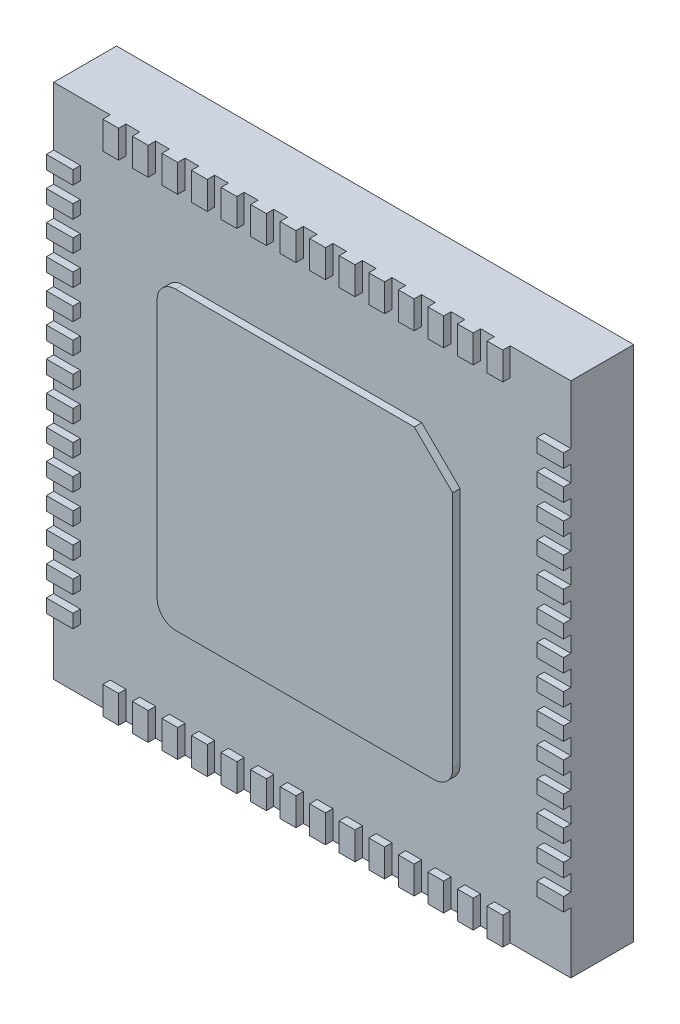
from build123d import *

# Parameters (mm, degrees)
PACKAGE_W               = 7
PACKAGE_H               = 7
BOSS_EXTRU_1_DEPTH      = 0.85
ESQUISSE2_W             = 0.213586618
ESQUISSE2_H             = 0.374942299
ESQUISSE2_W_2           = 0.360094548
ESQUISSE2_H_2           = 0.182510236
ESQUISSE2_W_3           = 0.360094549
BOSS_EXTRU_2_DEPTH      = 0.1
ESQUISSE3_R             = 0.166069215
ENL_V_MAT_EXTRU_1_DEPTH = 0.1
ENL_V_MAT_EXTRU_2_DEPTH = 0.02


with BuildPart() as part:
    # package → Boss.-Extru.1 (new body)
    with BuildSketch(Plane.XY):
        with Locations((26.809198807, 233.44048648)):
            Rectangle(PACKAGE_W, PACKAGE_H)
    extrude(amount=-BOSS_EXTRU_1_DEPTH)

    # Esquisse2 → Boss.-Extru.2 (add)
    with BuildSketch(Plane.XY):
        with BuildLine():
            Line((25.059198807, 231.44048648), (28.559198807, 231.44048648))
            ThreePointArc((28.559198807, 231.44048648), (28.735975502, 231.513709785), (28.809198807, 231.69048648))
            Line((28.809198807, 231.69048648), (28.809198807, 234.928046777))
            Line((28.809198807, 234.928046777), (28.290211106, 235.44048648))
            Line((28.290211106, 235.44048648), (25.059198807, 235.44048648))
            ThreePointArc((25.059198807, 235.44048648), (24.882422111, 235.367263175), (24.809198807, 235.19048648))
            Line((24.809198807, 235.19048648), (24.809198807, 231.69048648))
            ThreePointArc((24.809198807, 231.69048648), (24.882422111, 231.513709785), (25.059198807, 231.44048648))
        make_face()
        with Locations((24.180646365, 236.753015331)):
            Rectangle(ESQUISSE2_W, ESQUISSE2_H)
        with Locations((24.580646365, 236.753015331)):
            Rectangle(ESQUISSE2_W, ESQUISSE2_H)
        with Locations((24.980646365, 236.753015331)):
            Rectangle(ESQUISSE2_W, ESQUISSE2_H)
        with Locations((25.380646365, 236.753015331)):
            Rectangle(ESQUISSE2_W, ESQUISSE2_H)
        with Locations((25.780646365, 236.753015331)):
            Rectangle(ESQUISSE2_W, ESQUISSE2_H)
        with Locations((26.180646365, 236.753015331)):
            Rectangle(ESQUISSE2_W, ESQUISSE2_H)
        with Locations((26.580646365, 236.753015331)):
            Rectangle(ESQUISSE2_W, ESQUISSE2_H)
        with Locations((26.980646365, 236.753015331)):
            Rectangle(ESQUISSE2_W, ESQUISSE2_H)
        with Locations((27.380646365, 236.753015331)):
            Rectangle(ESQUISSE2_W, ESQUISSE2_H)
        with Locations((27.780646365, 236.753015331)):
            Rectangle(ESQUISSE2_W, ESQUISSE2_H)
        with Locations((28.180646365, 236.753015331)):
            Rectangle(ESQUISSE2_W, ESQUISSE2_H)
        with Locations((28.580646365, 236.753015331)):
            Rectangle(ESQUISSE2_W, ESQUISSE2_H)
        with Locations((28.980646365, 236.753015331)):
            Rectangle(ESQUISSE2_W, ESQUISSE2_H)
        with Locations((29.380646365, 236.753015331)):
            Rectangle(ESQUISSE2_W, ESQUISSE2_H)
        with Locations((23.489246081, 235.654646382)):
            Rectangle(ESQUISSE2_W_2, ESQUISSE2_H_2)
        with Locations((23.489246081, 236.054646382)):
            Rectangle(ESQUISSE2_W_2, ESQUISSE2_H_2)
        with Locations((23.489246081, 235.254646382)):
            Rectangle(ESQUISSE2_W_2, ESQUISSE2_H_2)
        with Locations((23.489246081, 234.854646382)):
            Rectangle(ESQUISSE2_W_2, ESQUISSE2_H_2)
        with Locations((23.489246081, 234.454646382)):
            Rectangle(ESQUISSE2_W_2, ESQUISSE2_H_2)
        with Locations((23.489246081, 234.054646382)):
            Rectangle(ESQUISSE2_W_2, ESQUISSE2_H_2)
        with Locations((23.489246081, 233.654646382)):
            Rectangle(ESQUISSE2_W_2, ESQUISSE2_H_2)
        with Locations((23.489246081, 233.254646382)):
            Rectangle(ESQUISSE2_W_2, ESQUISSE2_H_2)
        with Locations((23.489246081, 232.854646382)):
            Rectangle(ESQUISSE2_W_2, ESQUISSE2_H_2)
        with Locations((23.489246081, 232.454646382)):
            Rectangle(ESQUISSE2_W_2, ESQUISSE2_H_2)
        with Locations((23.489246081, 232.054646382)):
            Rectangle(ESQUISSE2_W_2, ESQUISSE2_H_2)
        with Locations((23.489246081, 231.654646382)):
            Rectangle(ESQUISSE2_W_2, ESQUISSE2_H_2)
        with Locations((23.489246081, 231.254646382)):
            Rectangle(ESQUISSE2_W_2, ESQUISSE2_H_2)
        with Locations((23.489246081, 230.854646382)):
            Rectangle(ESQUISSE2_W_2, ESQUISSE2_H_2)
        with Locations((29.380646365, 230.12795763)):
            Rectangle(ESQUISSE2_W, ESQUISSE2_H)
        with Locations((28.980646365, 230.12795763)):
            Rectangle(ESQUISSE2_W, ESQUISSE2_H)
        with Locations((28.580646365, 230.12795763)):
            Rectangle(ESQUISSE2_W, ESQUISSE2_H)
        with Locations((28.180646365, 230.12795763)):
            Rectangle(ESQUISSE2_W, ESQUISSE2_H)
        with Locations((27.780646365, 230.12795763)):
            Rectangle(ESQUISSE2_W, ESQUISSE2_H)
        with Locations((27.380646365, 230.12795763)):
            Rectangle(ESQUISSE2_W, ESQUISSE2_H)
        with Locations((26.980646365, 230.12795763)):
            Rectangle(ESQUISSE2_W, ESQUISSE2_H)
        with Locations((26.580646365, 230.12795763)):
            Rectangle(ESQUISSE2_W, ESQUISSE2_H)
        with Locations((26.180646365, 230.12795763)):
            Rectangle(ESQUISSE2_W, ESQUISSE2_H)
        with Locations((25.780646365, 230.12795763)):
            Rectangle(ESQUISSE2_W, ESQUISSE2_H)
        with Locations((25.380646365, 230.12795763)):
            Rectangle(ESQUISSE2_W, ESQUISSE2_H)
        with Locations((24.980646365, 230.12795763)):
            Rectangle(ESQUISSE2_W, ESQUISSE2_H)
        with Locations((24.580646365, 230.12795763)):
            Rectangle(ESQUISSE2_W, ESQUISSE2_H)
        with Locations((24.180646365, 230.12795763)):
            Rectangle(ESQUISSE2_W, ESQUISSE2_H)
        with Locations((30.129151533, 230.854646382)):
            Rectangle(ESQUISSE2_W_3, ESQUISSE2_H_2)
        with Locations((30.129151533, 231.254646382)):
            Rectangle(ESQUISSE2_W_3, ESQUISSE2_H_2)
        with Locations((30.129151533, 231.654646382)):
            Rectangle(ESQUISSE2_W_3, ESQUISSE2_H_2)
        with Locations((30.129151533, 232.054646382)):
            Rectangle(ESQUISSE2_W_3, ESQUISSE2_H_2)
        with Locations((30.129151533, 232.454646382)):
            Rectangle(ESQUISSE2_W_3, ESQUISSE2_H_2)
        with Locations((30.129151533, 232.854646382)):
            Rectangle(ESQUISSE2_W_3, ESQUISSE2_H_2)
        with Locations((30.129151533, 233.254646382)):
            Rectangle(ESQUISSE2_W_3, ESQUISSE2_H_2)
        with Locations((30.129151533, 233.654646382)):
            Rectangle(ESQUISSE2_W_3, ESQUISSE2_H_2)
        with Locations((30.129151533, 234.054646382)):
            Rectangle(ESQUISSE2_W_3, ESQUISSE2_H_2)
        with Locations((30.129151533, 234.454646382)):
            Rectangle(ESQUISSE2_W_3, ESQUISSE2_H_2)
        with Locations((30.129151533, 234.854646382)):
            Rectangle(ESQUISSE2_W_3, ESQUISSE2_H_2)
        with Locations((30.129151533, 235.254646382)):
            Rectangle(ESQUISSE2_W_3, ESQUISSE2_H_2)
        with Locations((30.129151533, 235.654646382)):
            Rectangle(ESQUISSE2_W_3, ESQUISSE2_H_2)
        with Locations((30.129151533, 236.054646382)):
            Rectangle(ESQUISSE2_W_3, ESQUISSE2_H_2)
    extrude(amount=BOSS_EXTRU_2_DEPTH)

    # Esquisse3 → Enlèv. mat.-Extru.1 (cut)
    with BuildSketch(Plane(origin=(0, 0, -0.85), x_dir=(-1, 0, 0), z_dir=(0, 0, -1))):
        with Locations((-29.974611492, 236.581266458)):
            Circle(ESQUISSE3_R)
    extrude(amount=-ENL_V_MAT_EXTRU_1_DEPTH, mode=Mode.SUBTRACT)

    # Esquisse4 → Enlèv. mat.-Extru.2 (cut)
    with BuildSketch(Plane(origin=(-0.370356703, 1.102355834, -0.85), x_dir=(-1, 0, 0), z_dir=(0, 0, -1))):
        Polygon((-28.682895901, 230.452000635), (-28.686659901, 230.484713635), (-28.838331901, 230.480821635), (-28.990003901, 230.476927635), (-28.990003901, 230.596414635), (-28.990003901, 230.715902635), (-28.856175901, 230.719267635), (-28.722347901, 230.722633635), (-28.722347901, 230.752370635), (-28.722347901, 230.782109635), (-28.856175901, 230.785472635), (-28.990003901, 230.788837635), (-28.990003901, 230.901457635), (-28.990003901, 231.014078635), (-28.841305901, 231.014078635), (-28.692607901, 231.014078635), (-28.692607901, 231.043818635), (-28.692607901, 231.073557635), (-28.876993901, 231.073557635), (-29.061378901, 231.073557635), (-29.061378901, 230.746422635), (-29.061378901, 230.419287635), (-28.870255901, 230.419287635), (-28.679131901, 230.419287635), align=None)
        with BuildLine():
            Line((-28.038336901, 230.556089635), (-28.038336901, 230.692890635))
            Line((-28.038336901, 230.692890635), (-27.936045901, 230.692890635))
            add(Edge.make_bspline(
                [(-27.936045901, 230.692890635), (-27.765671901, 230.692890635), (-27.699306901, 230.744596635), (-27.699384901, 230.877275635)],
                knots=[0, 0, 0, 0, 1, 1, 1, 1], degree=3))
            add(Edge.make_bspline(
                [(-27.699384901, 230.877275635), (-27.699473901, 230.963355635), (-27.727885901, 231.019005635), (-27.788523901, 231.051635635)],
                knots=[0, 0, 0, 0, 1, 1, 1, 1], degree=3))
            add(Edge.make_bspline(
                [(-27.788523901, 231.051635635), (-27.823602901, 231.070510635), (-27.851561901, 231.073534635), (-27.966063901, 231.070822635)],
                knots=[0, 0, 0, 0, 1, 1, 1, 1], degree=3))
            Line((-27.966063901, 231.070822635), (-28.101966901, 231.067608635))
            Line((-28.101966901, 231.067608635), (-28.099929901, 230.746420635))
            add(Edge.make_bspline(
                [(-28.099929901, 230.746420635), (-28.098817901, 230.569767635), (-28.097865901, 230.423895635), (-28.097865901, 230.422259635)],
                knots=[0, 0, 0, 0, 1, 1, 1, 1], degree=3))
            add(Edge.make_bspline(
                [(-28.097865901, 230.422259635), (-28.097865901, 230.420618635), (-28.084442901, 230.419285635), (-28.068085901, 230.419285635)],
                knots=[0, 0, 0, 0, 1, 1, 1, 1], degree=3))
            Line((-28.068085901, 230.419285635), (-28.038346901, 230.419285635))
            Line((-28.038346901, 230.419285635), (-28.038336901, 230.556089635))
        make_face()
        with BuildLine():
            Line((-28.038336901, 230.883224635), (-28.038336901, 231.014076635))
            Line((-28.038336901, 231.014076635), (-27.948527901, 231.014076635))
            add(Edge.make_bspline(
                [(-27.948527901, 231.014076635), (-27.816620901, 231.014076635), (-27.764732901, 230.977134635), (-27.764732901, 230.883222635)],
                knots=[0, 0, 0, 0, 1, 1, 1, 1], degree=3))
            add(Edge.make_bspline(
                [(-27.764732901, 230.883222635), (-27.764732901, 230.789310635), (-27.816620901, 230.752368635), (-27.948527901, 230.752368635)],
                knots=[0, 0, 0, 0, 1, 1, 1, 1], degree=3))
            Line((-27.948527901, 230.752368635), (-28.038336901, 230.752368635))
            Line((-28.038336901, 230.752368635), (-28.038336901, 230.883224635))
        make_face(mode=Mode.SUBTRACT)
        with BuildLine():
            Line((-26.848753901, 230.452550635), (-26.848753901, 230.485813635))
            Line((-26.848753901, 230.485813635), (-26.961421901, 230.480884635))
            add(Edge.make_bspline(
                [(-26.961421901, 230.480884635), (-27.105904901, 230.474566635), (-27.117372901, 230.478476635), (-27.092930901, 230.525741635)],
                knots=[0, 0, 0, 0, 1, 1, 1, 1], degree=3))
            add(Edge.make_bspline(
                [(-27.092930901, 230.525741635), (-27.082831901, 230.545270635), (-27.034841901, 230.603731635), (-26.986284901, 230.655653635)],
                knots=[0, 0, 0, 0, 1, 1, 1, 1], degree=3))
            add(Edge.make_bspline(
                [(-26.986284901, 230.655653635), (-26.937727901, 230.707574635), (-26.886919901, 230.771775635), (-26.873377901, 230.798321635)],
                knots=[0, 0, 0, 0, 1, 1, 1, 1], degree=3))
            add(Edge.make_bspline(
                [(-26.873377901, 230.798321635), (-26.839982901, 230.863779635), (-26.840408901, 230.956132635), (-26.874382901, 231.011063635)],
                knots=[0, 0, 0, 0, 1, 1, 1, 1], degree=3))
            add(Edge.make_bspline(
                [(-26.874382901, 231.011063635), (-26.934701901, 231.108662635), (-27.096131901, 231.109470635), (-27.154897901, 231.012466635)],
                knots=[0, 0, 0, 0, 1, 1, 1, 1], degree=3))
            add(Edge.make_bspline(
                [(-27.154897901, 231.012466635), (-27.194417901, 230.947235635), (-27.198240901, 230.922146635), (-27.170894901, 230.907510635)],
                knots=[0, 0, 0, 0, 1, 1, 1, 1], degree=3))
            add(Edge.make_bspline(
                [(-27.170894901, 230.907510635), (-27.149762901, 230.896199635), (-27.143994901, 230.900337635), (-27.122700901, 230.942075635)],
                knots=[0, 0, 0, 0, 1, 1, 1, 1], degree=3))
            add(Edge.make_bspline(
                [(-27.122700901, 230.942075635), (-27.095079901, 230.996219635), (-27.068447901, 231.014075635), (-27.015319901, 231.014075635)],
                knots=[0, 0, 0, 0, 1, 1, 1, 1], degree=3))
            add(Edge.make_bspline(
                [(-27.015319901, 231.014075635), (-26.961995901, 231.014075635), (-26.935881901, 230.996306635), (-26.920438901, 230.949514635)],
                knots=[0, 0, 0, 0, 1, 1, 1, 1], degree=3))
            add(Edge.make_bspline(
                [(-26.920438901, 230.949514635), (-26.896851901, 230.878039635), (-26.921073901, 230.824643635), (-27.035422901, 230.695952635)],
                knots=[0, 0, 0, 0, 1, 1, 1, 1], degree=3))
            add(Edge.make_bspline(
                [(-27.035422901, 230.695952635), (-27.131392901, 230.587953635), (-27.193375901, 230.487724635), (-27.193640901, 230.440101635)],
                knots=[0, 0, 0, 0, 1, 1, 1, 1], degree=3))
            add(Edge.make_bspline(
                [(-27.193640901, 230.440101635), (-27.193748901, 230.421226635), (-27.177657901, 230.419284635), (-27.021267901, 230.419284635)],
                knots=[0, 0, 0, 0, 1, 1, 1, 1], degree=3))
            Line((-27.021267901, 230.419284635), (-26.848778901, 230.419284635))
            Line((-26.848778901, 230.419284635), (-26.848753901, 230.452550635))
        make_face()
        with BuildLine():
            Line((-26.398895901, 230.745900635), (-26.395130901, 230.776160635))
            Line((-26.395130901, 230.776160635), (-26.580305901, 230.776160635))
            Line((-26.580305901, 230.776160635), (-26.765481901, 230.776160635))
            Line((-26.765481901, 230.776160635), (-26.765481901, 230.748404635))
            add(Edge.make_bspline(
                [(-26.765481901, 230.748404635), (-26.765481901, 230.733137635), (-26.763258901, 230.718416635), (-26.760541901, 230.715690635)],
                knots=[0, 0, 0, 0, 1, 1, 1, 1], degree=3))
            add(Edge.make_bspline(
                [(-26.760541901, 230.715690635), (-26.757826901, 230.712965635), (-26.676189901, 230.711838635), (-26.579129901, 230.713203635)],
                knots=[0, 0, 0, 0, 1, 1, 1, 1], degree=3))
            Line((-26.579129901, 230.713203635), (-26.402658901, 230.715637635))
            Line((-26.402658901, 230.715637635), (-26.398895901, 230.745900635))
        make_face()
        with BuildLine():
            Line((-26.243941901, 232.183604635), (-26.216079901, 232.213479635))
            Line((-26.216079901, 232.213479635), (-26.251178901, 232.250206635))
            add(Edge.make_bspline(
                [(-26.251178901, 232.250206635), (-26.270482901, 232.270407635), (-26.289436901, 232.286933635), (-26.293297901, 232.286933635)],
                knots=[0, 0, 0, 0, 1, 1, 1, 1], degree=3))
            add(Edge.make_bspline(
                [(-26.293297901, 232.286933635), (-26.297160901, 232.286933635), (-26.315316901, 232.272863635), (-26.333645901, 232.255665635)],
                knots=[0, 0, 0, 0, 1, 1, 1, 1], degree=3))
            add(Edge.make_bspline(
                [(-26.333645901, 232.255665635), (-26.469469901, 232.128229635), (-26.682085901, 232.011372635), (-26.872544901, 231.959478635)],
                knots=[0, 0, 0, 0, 1, 1, 1, 1], degree=3))
            add(Edge.make_bspline(
                [(-26.872544901, 231.959478635), (-27.012691901, 231.921293635), (-27.227176901, 231.908300635), (-27.373231901, 231.929148635)],
                knots=[0, 0, 0, 0, 1, 1, 1, 1], degree=3))
            add(Edge.make_bspline(
                [(-27.373231901, 231.929148635), (-27.600369901, 231.961569635), (-27.859466901, 232.079457635), (-28.026440901, 232.226355635)],
                knots=[0, 0, 0, 0, 1, 1, 1, 1], degree=3))
            add(Edge.make_bspline(
                [(-28.026440901, 232.226355635), (-28.067554901, 232.262525635), (-28.067628901, 232.262762635), (-28.032388901, 232.245294635)],
                knots=[0, 0, 0, 0, 1, 1, 1, 1], degree=3))
            add(Edge.make_bspline(
                [(-28.032388901, 232.245294635), (-27.934855901, 232.196943635), (-27.802320901, 232.249781635), (-27.757320901, 232.354954635)],
                knots=[0, 0, 0, 0, 1, 1, 1, 1], degree=3))
            add(Edge.make_bspline(
                [(-27.757320901, 232.354954635), (-27.736037901, 232.404693635), (-27.736428901, 232.481619635), (-27.758193901, 232.523676635)],
                knots=[0, 0, 0, 0, 1, 1, 1, 1], degree=3))
            add(Edge.make_bspline(
                [(-27.758193901, 232.523676635), (-27.782659901, 232.570993635), (-27.851565901, 232.628189635), (-27.895811901, 232.637907635)],
                knots=[0, 0, 0, 0, 1, 1, 1, 1], degree=3))
            add(Edge.make_bspline(
                [(-27.895811901, 232.637907635), (-28.063272901, 232.674687635), (-28.196784901, 232.518418635), (-28.139774901, 232.352360635)],
                knots=[0, 0, 0, 0, 1, 1, 1, 1], degree=3))
            add(Edge.make_bspline(
                [(-28.139774901, 232.352360635), (-28.121341901, 232.298669635), (-28.253070901, 232.473935635), (-28.314120901, 232.584329635)],
                knots=[0, 0, 0, 0, 1, 1, 1, 1], degree=3))
            add(Edge.make_bspline(
                [(-28.314120901, 232.584329635), (-28.358995901, 232.665473635), (-28.417219901, 232.824067635), (-28.437529901, 232.920475635)],
                knots=[0, 0, 0, 0, 1, 1, 1, 1], degree=3))
            add(Edge.make_bspline(
                [(-28.437529901, 232.920475635), (-28.519806901, 233.311033635), (-28.410471901, 233.733223635), (-28.152908901, 234.019525635)],
                knots=[0, 0, 0, 0, 1, 1, 1, 1], degree=3))
            add(Edge.make_bspline(
                [(-28.152908901, 234.019525635), (-28.122613901, 234.053199635), (-28.097827901, 234.084392635), (-28.097827901, 234.088841635)],
                knots=[0, 0, 0, 0, 1, 1, 1, 1], degree=3))
            add(Edge.make_bspline(
                [(-28.097827901, 234.088841635), (-28.097827901, 234.093290635), (-28.114613901, 234.113715635), (-28.135128901, 234.134231635)],
                knots=[0, 0, 0, 0, 1, 1, 1, 1], degree=3))
            Line((-28.135128901, 234.134231635), (-28.172418901, 234.171531635))
            Line((-28.172418901, 234.171531635), (-28.231580901, 234.106550635))
            add(Edge.make_bspline(
                [(-28.231580901, 234.106550635), (-28.394784901, 233.927291635), (-28.516620901, 233.673347635), (-28.562390901, 233.417037635)],
                knots=[0, 0, 0, 0, 1, 1, 1, 1], degree=3))
            add(Edge.make_bspline(
                [(-28.562390901, 233.417037635), (-28.582101901, 233.306659635), (-28.578760901, 233.036879635), (-28.556352901, 232.929308635)],
                knots=[0, 0, 0, 0, 1, 1, 1, 1], degree=3))
            add(Edge.make_bspline(
                [(-28.556352901, 232.929308635), (-28.430736901, 232.326329635), (-27.974202901, 231.896504635), (-27.368563901, 231.811008635)],
                knots=[0, 0, 0, 0, 1, 1, 1, 1], degree=3))
            add(Edge.make_bspline(
                [(-27.368563901, 231.811008635), (-27.254207901, 231.794863635), (-27.035359901, 231.806044635), (-26.904539901, 231.834714635)],
                knots=[0, 0, 0, 0, 1, 1, 1, 1], degree=3))
            add(Edge.make_bspline(
                [(-26.904539901, 231.834714635), (-26.738693901, 231.871060635), (-26.604921901, 231.925152635), (-26.456190901, 232.016007635)],
                knots=[0, 0, 0, 0, 1, 1, 1, 1], degree=3))
            add(Edge.make_bspline(
                [(-26.456190901, 232.016007635), (-26.400996901, 232.049724635), (-26.278850901, 232.146173635), (-26.243941901, 232.183604635)],
                knots=[0, 0, 0, 0, 1, 1, 1, 1], degree=3))
        make_face()
        with BuildLine():
            Line((-26.988920901, 232.067859635), (-26.897118901, 232.035865635))
            Line((-26.897118901, 232.035865635), (-26.801272901, 232.069009635))
            add(Edge.make_bspline(
                [(-26.801272901, 232.069009635), (-26.711475901, 232.100061635), (-26.704722901, 232.104795635), (-26.694277901, 232.143987635)],
                knots=[0, 0, 0, 0, 1, 1, 1, 1], degree=3))
            add(Edge.make_bspline(
                [(-26.694277901, 232.143987635), (-26.615948901, 232.437908635), (-26.677391901, 232.827784635), (-26.844262901, 233.095688635)],
                knots=[0, 0, 0, 0, 1, 1, 1, 1], degree=3))
            add(Edge.make_bspline(
                [(-26.844262901, 233.095688635), (-27.062930901, 233.446758635), (-27.361565901, 233.645788635), (-27.765689901, 233.709795635)],
                knots=[0, 0, 0, 0, 1, 1, 1, 1], degree=3))
            add(Edge.make_bspline(
                [(-27.765689901, 233.709795635), (-27.917309901, 233.733809635), (-28.009677901, 233.725095635), (-28.111372901, 233.677184635)],
                knots=[0, 0, 0, 0, 1, 1, 1, 1], degree=3))
            add(Edge.make_bspline(
                [(-28.111372901, 233.677184635), (-28.285127901, 233.595324635), (-28.366557901, 233.452932635), (-28.357725901, 233.246396635)],
                knots=[0, 0, 0, 0, 1, 1, 1, 1], degree=3))
            add(Edge.make_bspline(
                [(-28.357725901, 233.246396635), (-28.352688901, 233.128611635), (-28.316381901, 233.045203635), (-28.234506901, 232.963328635)],
                knots=[0, 0, 0, 0, 1, 1, 1, 1], degree=3))
            add(Edge.make_bspline(
                [(-28.234506901, 232.963328635), (-28.158198901, 232.887020635), (-28.074743901, 232.847834635), (-27.960330901, 232.834591635)],
                knots=[0, 0, 0, 0, 1, 1, 1, 1], degree=3))
            add(Edge.make_bspline(
                [(-27.960330901, 232.834591635), (-27.812487901, 232.817478635), (-27.740352901, 232.784897635), (-27.649779901, 232.694325635)],
                knots=[0, 0, 0, 0, 1, 1, 1, 1], degree=3))
            add(Edge.make_bspline(
                [(-27.649779901, 232.694325635), (-27.554761901, 232.599307635), (-27.526128901, 232.401900635), (-27.588964901, 232.275047635)],
                knots=[0, 0, 0, 0, 1, 1, 1, 1], degree=3))
            add(Edge.make_bspline(
                [(-27.588964901, 232.275047635), (-27.606792901, 232.239062635), (-27.628202901, 232.200098635), (-27.636548901, 232.188460635)],
                knots=[0, 0, 0, 0, 1, 1, 1, 1], degree=3))
            add(Edge.make_bspline(
                [(-27.636548901, 232.188460635), (-27.649923901, 232.169807635), (-27.643414901, 232.159943635), (-27.581579901, 232.105189635)],
                knots=[0, 0, 0, 0, 1, 1, 1, 1], degree=3))
            add(Edge.make_bspline(
                [(-27.581579901, 232.105189635), (-27.519765901, 232.050454635), (-27.500692901, 232.040760635), (-27.420985901, 232.023562635)],
                knots=[0, 0, 0, 0, 1, 1, 1, 1], degree=3))
            add(Edge.make_bspline(
                [(-27.420985901, 232.023562635), (-27.371237901, 232.012827635), (-27.324590901, 232.003459635), (-27.317323901, 232.002744635)],
                knots=[0, 0, 0, 0, 1, 1, 1, 1], degree=3))
            add(Edge.make_bspline(
                [(-27.317323901, 232.002744635), (-27.310057901, 232.002030635), (-27.287791901, 232.032223635), (-27.267847901, 232.069844635)],
                knots=[0, 0, 0, 0, 1, 1, 1, 1], degree=3))
            add(Edge.make_bspline(
                [(-27.267847901, 232.069844635), (-27.203229901, 232.191714635), (-27.176485901, 232.301219635), (-27.177056901, 232.441579635)],
                knots=[0, 0, 0, 0, 1, 1, 1, 1], degree=3))
            add(Edge.make_bspline(
                [(-27.177056901, 232.441579635), (-27.177611901, 232.578706635), (-27.196844901, 232.663001635), (-27.252911901, 232.774069635)],
                knots=[0, 0, 0, 0, 1, 1, 1, 1], degree=3))
            add(Edge.make_bspline(
                [(-27.252911901, 232.774069635), (-27.379430901, 233.024700635), (-27.598237901, 233.172153635), (-27.898785901, 233.209319635)],
                knots=[0, 0, 0, 0, 1, 1, 1, 1], degree=3))
            add(Edge.make_bspline(
                [(-27.898785901, 233.209319635), (-27.990144901, 233.220616635), (-28.020079901, 233.295789635), (-27.948481901, 233.334108635)],
                knots=[0, 0, 0, 0, 1, 1, 1, 1], degree=3))
            add(Edge.make_bspline(
                [(-27.948481901, 233.334108635), (-27.923583901, 233.347432635), (-27.902936901, 233.347556635), (-27.826745901, 233.334848635)],
                knots=[0, 0, 0, 0, 1, 1, 1, 1], degree=3))
            add(Edge.make_bspline(
                [(-27.826745901, 233.334848635), (-27.510508901, 233.282091635), (-27.270265901, 233.109019635), (-27.139966901, 232.840091635)],
                knots=[0, 0, 0, 0, 1, 1, 1, 1], degree=3))
            add(Edge.make_bspline(
                [(-27.139966901, 232.840091635), (-27.059856901, 232.674749635), (-27.045239901, 232.607155635), (-27.046074901, 232.405893635)],
                knots=[0, 0, 0, 0, 1, 1, 1, 1], degree=3))
            add(Edge.make_bspline(
                [(-27.046074901, 232.405893635), (-27.046709901, 232.254406635), (-27.049990901, 232.226284635), (-27.073096901, 232.174937635)],
                knots=[0, 0, 0, 0, 1, 1, 1, 1], degree=3))
            add(Edge.make_bspline(
                [(-27.073096901, 232.174937635), (-27.087566901, 232.142781635), (-27.095197901, 232.112731635), (-27.090061901, 232.108162635)],
                knots=[0, 0, 0, 0, 1, 1, 1, 1], degree=3))
            add(Edge.make_bspline(
                [(-27.090061901, 232.108162635), (-27.084925901, 232.103592635), (-27.039411901, 232.085455635), (-26.988920901, 232.067859635)],
                knots=[0, 0, 0, 0, 1, 1, 1, 1], degree=3))
        make_face()
        with BuildLine():
            Line((-26.200308901, 232.581385635), (-26.157213901, 232.643867635))
            Line((-26.157213901, 232.643867635), (-26.182079901, 232.768935635))
            add(Edge.make_bspline(
                [(-26.182079901, 232.768935635), (-26.256280901, 233.142099635), (-26.416912901, 233.451646635), (-26.663512901, 233.696686635)],
                knots=[0, 0, 0, 0, 1, 1, 1, 1], degree=3))
            add(Edge.make_bspline(
                [(-26.663512901, 233.696686635), (-26.925578901, 233.957094635), (-27.245255901, 234.129705635), (-27.600755901, 234.202754635)],
                knots=[0, 0, 0, 0, 1, 1, 1, 1], degree=3))
            Line((-27.600755901, 234.202754635), (-27.711200901, 234.225449635))
            Line((-27.711200901, 234.225449635), (-27.803997901, 234.169438635))
            add(Edge.make_bspline(
                [(-27.803997901, 234.169438635), (-27.855035901, 234.138632635), (-27.915473901, 234.098030635), (-27.938303901, 234.079212635)],
                knots=[0, 0, 0, 0, 1, 1, 1, 1], degree=3))
            Line((-27.938303901, 234.079212635), (-27.979812901, 234.044996635))
            Line((-27.979812901, 234.044996635), (-27.976359901, 233.954063635))
            Line((-27.976359901, 233.954063635), (-27.972909901, 233.863131635))
            Line((-27.972909901, 233.863131635), (-27.931273901, 233.860211635))
            add(Edge.make_bspline(
                [(-27.931273901, 233.860211635), (-27.689406901, 233.843249635), (-27.524540901, 233.802663635), (-27.339541901, 233.714538635)],
                knots=[0, 0, 0, 0, 1, 1, 1, 1], degree=3))
            add(Edge.make_bspline(
                [(-27.339541901, 233.714538635), (-26.903911901, 233.507024635), (-26.617007901, 233.121080635), (-26.545849901, 232.646860635)],
                knots=[0, 0, 0, 0, 1, 1, 1, 1], degree=3))
            add(Edge.make_bspline(
                [(-26.545849901, 232.646860635), (-26.535795901, 232.579840635), (-26.527567901, 232.498205635), (-26.527567901, 232.465448635)],
                knots=[0, 0, 0, 0, 1, 1, 1, 1], degree=3))
            Line((-26.527567901, 232.465448635), (-26.527567901, 232.405891635))
            Line((-26.527567901, 232.405891635), (-26.423478901, 232.406104635))
            Line((-26.423478901, 232.406104635), (-26.319389901, 232.406318635))
            Line((-26.319389901, 232.406318635), (-26.281397901, 232.462610635))
            add(Edge.make_bspline(
                [(-26.281397901, 232.462610635), (-26.260501901, 232.493571635), (-26.224011901, 232.547019635), (-26.200308901, 232.581385635)],
                knots=[0, 0, 0, 0, 1, 1, 1, 1], degree=3))
        make_face()
        with BuildLine():
            Line((-27.182201901, 234.356622635), (-27.295578901, 234.356814635))
            Line((-27.295578901, 234.356814635), (-27.309709901, 234.319383635))
            add(Edge.make_bspline(
                [(-27.309709901, 234.319383635), (-27.327103901, 234.273295635), (-27.323478901, 234.267053635), (-27.268846901, 234.249022635)],
                knots=[0, 0, 0, 0, 1, 1, 1, 1], degree=3))
            add(Edge.make_bspline(
                [(-27.268846901, 234.249022635), (-27.189405901, 234.222804635), (-26.999038901, 234.128416635), (-26.914384901, 234.073271635)],
                knots=[0, 0, 0, 0, 1, 1, 1, 1], degree=3))
            add(Edge.make_bspline(
                [(-26.914384901, 234.073271635), (-26.792558901, 233.993914635), (-26.623325901, 233.856012635), (-26.548253901, 233.774925635)],
                knots=[0, 0, 0, 0, 1, 1, 1, 1], degree=3))
            add(Edge.make_bspline(
                [(-26.548253901, 233.774925635), (-26.427699901, 233.644714635), (-26.306354901, 233.470627635), (-26.227655901, 233.314985635)],
                knots=[0, 0, 0, 0, 1, 1, 1, 1], degree=3))
            add(Edge.make_bspline(
                [(-26.227655901, 233.314985635), (-26.184910901, 233.230449635), (-26.143485901, 233.141208635), (-26.135600901, 233.116673635)],
                knots=[0, 0, 0, 0, 1, 1, 1, 1], degree=3))
            add(Edge.make_bspline(
                [(-26.135600901, 233.116673635), (-26.120434901, 233.069481635), (-26.096120901, 233.060205635), (-26.050952901, 233.084378635)],
                knots=[0, 0, 0, 0, 1, 1, 1, 1], degree=3))
            add(Edge.make_bspline(
                [(-26.050952901, 233.084378635), (-26.030579901, 233.095274635), (-26.027939901, 233.110196635), (-26.027939901, 233.214449635)],
                knots=[0, 0, 0, 0, 1, 1, 1, 1], degree=3))
            add(Edge.make_bspline(
                [(-26.027939901, 233.214449635), (-26.027939901, 233.518850635), (-26.162504901, 233.818680635), (-26.399306901, 234.041908635)],
                knots=[0, 0, 0, 0, 1, 1, 1, 1], degree=3))
            add(Edge.make_bspline(
                [(-26.399306901, 234.041908635), (-26.614220901, 234.244502635), (-26.891948901, 234.356145635), (-27.182201901, 234.356622635)],
                knots=[0, 0, 0, 0, 1, 1, 1, 1], degree=3))
        make_face()
        with BuildLine():
            add(Edge.make_bspline(
                [(-28.303410901, 230.427253635), (-28.243523901, 230.455675635), (-28.216872901, 230.505825635), (-28.216818901, 230.590201635)],
                knots=[0, 0, 0, 0, 1, 1, 1, 1], degree=3))
            add(Edge.make_bspline(
                [(-28.216818901, 230.590201635), (-28.216818901, 230.655069635), (-28.219926901, 230.663137635), (-28.261383901, 230.704361635)],
                knots=[0, 0, 0, 0, 1, 1, 1, 1], degree=3))
            add(Edge.make_bspline(
                [(-28.261383901, 230.704361635), (-28.288274901, 230.731101635), (-28.334342901, 230.758928635), (-28.377367901, 230.774420635)],
                knots=[0, 0, 0, 0, 1, 1, 1, 1], degree=3))
            add(Edge.make_bspline(
                [(-28.377367901, 230.774420635), (-28.470083901, 230.807804635), (-28.503146901, 230.827086635), (-28.531048901, 230.864044635)],
                knots=[0, 0, 0, 0, 1, 1, 1, 1], degree=3))
            add(Edge.make_bspline(
                [(-28.531048901, 230.864044635), (-28.550946901, 230.890399635), (-28.552111901, 230.900170635), (-28.540118901, 230.940193635)],
                knots=[0, 0, 0, 0, 1, 1, 1, 1], degree=3))
            add(Edge.make_bspline(
                [(-28.540118901, 230.940193635), (-28.513224901, 231.029958635), (-28.383243901, 231.048341635), (-28.311957901, 230.972460635)],
                knots=[0, 0, 0, 0, 1, 1, 1, 1], degree=3))
            add(Edge.make_bspline(
                [(-28.311957901, 230.972460635), (-28.282086901, 230.940664635), (-28.268142901, 230.936903635), (-28.241853901, 230.953550635)],
                knots=[0, 0, 0, 0, 1, 1, 1, 1], degree=3))
            add(Edge.make_bspline(
                [(-28.241853901, 230.953550635), (-28.216505901, 230.969603635), (-28.269018901, 231.035724635), (-28.328606901, 231.062786635)],
                knots=[0, 0, 0, 0, 1, 1, 1, 1], degree=3))
            add(Edge.make_bspline(
                [(-28.328606901, 231.062786635), (-28.415920901, 231.102439635), (-28.515849901, 231.084037635), (-28.574219901, 231.017557635)],
                knots=[0, 0, 0, 0, 1, 1, 1, 1], degree=3))
            add(Edge.make_bspline(
                [(-28.574219901, 231.017557635), (-28.603889901, 230.983765635), (-28.609335901, 230.967543635), (-28.609335901, 230.912963635)],
                knots=[0, 0, 0, 0, 1, 1, 1, 1], degree=3))
            add(Edge.make_bspline(
                [(-28.609335901, 230.912963635), (-28.609335901, 230.858388635), (-28.603888901, 230.842159635), (-28.574234901, 230.808385635)],
                knots=[0, 0, 0, 0, 1, 1, 1, 1], degree=3))
            add(Edge.make_bspline(
                [(-28.574234901, 230.808385635), (-28.554927901, 230.786398635), (-28.516118901, 230.758625635), (-28.487989901, 230.746670635)],
                knots=[0, 0, 0, 0, 1, 1, 1, 1], degree=3))
            add(Edge.make_bspline(
                [(-28.487989901, 230.746670635), (-28.318359901, 230.674574635), (-28.311229901, 230.670302635), (-28.294767901, 230.630904635)],
                knots=[0, 0, 0, 0, 1, 1, 1, 1], degree=3))
            add(Edge.make_bspline(
                [(-28.294767901, 230.630904635), (-28.272606901, 230.577866635), (-28.283673901, 230.532228635), (-28.327672901, 230.495206635)],
                knots=[0, 0, 0, 0, 1, 1, 1, 1], degree=3))
            add(Edge.make_bspline(
                [(-28.327672901, 230.495206635), (-28.359812901, 230.468162635), (-28.372443901, 230.464994635), (-28.429334901, 230.469711635)],
                knots=[0, 0, 0, 0, 1, 1, 1, 1], degree=3))
            add(Edge.make_bspline(
                [(-28.429334901, 230.469711635), (-28.486014901, 230.474412635), (-28.499527901, 230.480805635), (-28.535320901, 230.519862635)],
                knots=[0, 0, 0, 0, 1, 1, 1, 1], degree=3))
            add(Edge.make_bspline(
                [(-28.535320901, 230.519862635), (-28.571735901, 230.559597635), (-28.579532901, 230.563173635), (-28.604735901, 230.551689635)],
                knots=[0, 0, 0, 0, 1, 1, 1, 1], degree=3))
            add(Edge.make_bspline(
                [(-28.604735901, 230.551689635), (-28.638485901, 230.536312635), (-28.639273901, 230.528708635), (-28.610663901, 230.494445635)],
                knots=[0, 0, 0, 0, 1, 1, 1, 1], degree=3))
            add(Edge.make_bspline(
                [(-28.610663901, 230.494445635), (-28.559959901, 230.433721635), (-28.502927901, 230.407388635), (-28.422113901, 230.407388635)],
                knots=[0, 0, 0, 0, 1, 1, 1, 1], degree=3))
            add(Edge.make_bspline(
                [(-28.422113901, 230.407388635), (-28.374979901, 230.407388635), (-28.329090901, 230.415069635), (-28.303410901, 230.427253635)],
                knots=[0, 0, 0, 0, 1, 1, 1, 1], degree=3))
        make_face()
        with BuildLine():
            add(Edge.make_bspline(
                [(-27.347163901, 230.434397635), (-27.287024901, 230.474569635), (-27.262877901, 230.529830635), (-27.268344901, 230.614767635)],
                knots=[0, 0, 0, 0, 1, 1, 1, 1], degree=3))
            add(Edge.make_bspline(
                [(-27.268344901, 230.614767635), (-27.272562901, 230.680280635), (-27.276451901, 230.688504635), (-27.322595901, 230.729453635)],
                knots=[0, 0, 0, 0, 1, 1, 1, 1], degree=3))
            add(Edge.make_bspline(
                [(-27.322595901, 230.729453635), (-27.359912901, 230.762569635), (-27.367855901, 230.775272635), (-27.354461901, 230.780412635)],
                knots=[0, 0, 0, 0, 1, 1, 1, 1], degree=3))
            add(Edge.make_bspline(
                [(-27.354461901, 230.780412635), (-27.324495901, 230.791910635), (-27.288990901, 230.862768635), (-27.288943901, 230.911166635)],
                knots=[0, 0, 0, 0, 1, 1, 1, 1], degree=3))
            add(Edge.make_bspline(
                [(-27.288943901, 230.911166635), (-27.288854901, 230.978662635), (-27.320518901, 231.035312635), (-27.373332901, 231.062255635)],
                knots=[0, 0, 0, 0, 1, 1, 1, 1], degree=3))
            add(Edge.make_bspline(
                [(-27.373332901, 231.062255635), (-27.456159901, 231.104511635), (-27.533694901, 231.085948635), (-27.591627901, 231.009994635)],
                knots=[0, 0, 0, 0, 1, 1, 1, 1], degree=3))
            add(Edge.make_bspline(
                [(-27.591627901, 231.009994635), (-27.628107901, 230.962167635), (-27.629401901, 230.947511635), (-27.598599901, 230.931026635)],
                knots=[0, 0, 0, 0, 1, 1, 1, 1], degree=3))
            add(Edge.make_bspline(
                [(-27.598599901, 230.931026635), (-27.578684901, 230.920366635), (-27.572398901, 230.923962635), (-27.556193901, 230.955299635)],
                knots=[0, 0, 0, 0, 1, 1, 1, 1], degree=3))
            add(Edge.make_bspline(
                [(-27.556193901, 230.955299635), (-27.501618901, 231.060837635), (-27.360274901, 231.024457635), (-27.360274901, 230.904873635)],
                knots=[0, 0, 0, 0, 1, 1, 1, 1], degree=3))
            add(Edge.make_bspline(
                [(-27.360274901, 230.904873635), (-27.360274901, 230.845268635), (-27.399948901, 230.803403635), (-27.466525901, 230.792757635)],
                knots=[0, 0, 0, 0, 1, 1, 1, 1], degree=3))
            add(Edge.make_bspline(
                [(-27.466525901, 230.792757635), (-27.507345901, 230.786230635), (-27.514919901, 230.780602635), (-27.514919901, 230.756800635)],
                knots=[0, 0, 0, 0, 1, 1, 1, 1], degree=3))
            add(Edge.make_bspline(
                [(-27.514919901, 230.756800635), (-27.514919901, 230.732381635), (-27.509207901, 230.728580635), (-27.472502901, 230.728580635)],
                knots=[0, 0, 0, 0, 1, 1, 1, 1], degree=3))
            add(Edge.make_bspline(
                [(-27.472502901, 230.728580635), (-27.387604901, 230.728580635), (-27.337121901, 230.679899635), (-27.336806901, 230.597726635)],
                knots=[0, 0, 0, 0, 1, 1, 1, 1], degree=3))
            add(Edge.make_bspline(
                [(-27.336806901, 230.597726635), (-27.336515901, 230.524615635), (-27.372877901, 230.479600635), (-27.439405901, 230.470677635)],
                knots=[0, 0, 0, 0, 1, 1, 1, 1], degree=3))
            add(Edge.make_bspline(
                [(-27.439405901, 230.470677635), (-27.494320901, 230.463311635), (-27.557427901, 230.491616635), (-27.569268901, 230.528925635)],
                knots=[0, 0, 0, 0, 1, 1, 1, 1], degree=3))
            add(Edge.make_bspline(
                [(-27.569268901, 230.528925635), (-27.576263901, 230.550959635), (-27.605440901, 230.556511635), (-27.630517901, 230.540577635)],
                knots=[0, 0, 0, 0, 1, 1, 1, 1], degree=3))
            add(Edge.make_bspline(
                [(-27.630517901, 230.540577635), (-27.651449901, 230.527274635), (-27.608457901, 230.460886635), (-27.559637901, 230.431121635)],
                knots=[0, 0, 0, 0, 1, 1, 1, 1], degree=3))
            add(Edge.make_bspline(
                [(-27.559637901, 230.431121635), (-27.503805901, 230.397079635), (-27.400644901, 230.398670635), (-27.347163901, 230.434397635)],
                knots=[0, 0, 0, 0, 1, 1, 1, 1], degree=3))
        make_face()
        with BuildLine():
            add(Edge.make_bspline(
                [(-26.003960901, 230.429090635), (-25.957467901, 230.453428635), (-25.908981901, 230.534969635), (-25.908981901, 230.588824635)],
                knots=[0, 0, 0, 0, 1, 1, 1, 1], degree=3))
            add(Edge.make_bspline(
                [(-25.908981901, 230.588824635), (-25.908981901, 230.676108635), (-25.968530901, 230.733522635), (-26.116414901, 230.788818635)],
                knots=[0, 0, 0, 0, 1, 1, 1, 1], degree=3))
            add(Edge.make_bspline(
                [(-26.116414901, 230.788818635), (-26.209307901, 230.823552635), (-26.242065901, 230.856847635), (-26.242065901, 230.916528635)],
                knots=[0, 0, 0, 0, 1, 1, 1, 1], degree=3))
            add(Edge.make_bspline(
                [(-26.242065901, 230.916528635), (-26.242065901, 231.021473635), (-26.101986901, 231.058797635), (-26.017634901, 230.976327635)],
                knots=[0, 0, 0, 0, 1, 1, 1, 1], degree=3))
            add(Edge.make_bspline(
                [(-26.017634901, 230.976327635), (-25.991503901, 230.950778635), (-25.974484901, 230.942965635), (-25.957035901, 230.948503635)],
                knots=[0, 0, 0, 0, 1, 1, 1, 1], degree=3))
            add(Edge.make_bspline(
                [(-25.957035901, 230.948503635), (-25.925480901, 230.958520635), (-25.926438901, 230.969037635), (-25.962851901, 231.012312635)],
                knots=[0, 0, 0, 0, 1, 1, 1, 1], degree=3))
            add(Edge.make_bspline(
                [(-25.962851901, 231.012312635), (-26.045421901, 231.110440635), (-26.217433901, 231.105070635), (-26.287289901, 231.002183635)],
                knots=[0, 0, 0, 0, 1, 1, 1, 1], degree=3))
            add(Edge.make_bspline(
                [(-26.287289901, 231.002183635), (-26.310554901, 230.967919635), (-26.314668901, 230.949445635), (-26.310522901, 230.897832635)],
                knots=[0, 0, 0, 0, 1, 1, 1, 1], degree=3))
            add(Edge.make_bspline(
                [(-26.310522901, 230.897832635), (-26.303783901, 230.813900635), (-26.266925901, 230.776641635), (-26.142384901, 230.727874635)],
                knots=[0, 0, 0, 0, 1, 1, 1, 1], degree=3))
            add(Edge.make_bspline(
                [(-26.142384901, 230.727874635), (-26.037024901, 230.686619635), (-25.980354901, 230.638747635), (-25.980354901, 230.590999635)],
                knots=[0, 0, 0, 0, 1, 1, 1, 1], degree=3))
            add(Edge.make_bspline(
                [(-25.980354901, 230.590999635), (-25.980354901, 230.459988635), (-26.164145901, 230.420820635), (-26.252403901, 230.533022635)],
                knots=[0, 0, 0, 0, 1, 1, 1, 1], degree=3))
            add(Edge.make_bspline(
                [(-26.252403901, 230.533022635), (-26.270087901, 230.555504635), (-26.283381901, 230.561854635), (-26.301037901, 230.556250635)],
                knots=[0, 0, 0, 0, 1, 1, 1, 1], degree=3))
            add(Edge.make_bspline(
                [(-26.301037901, 230.556250635), (-26.314398901, 230.552009635), (-26.325333901, 230.541280635), (-26.325333901, 230.532408635)],
                knots=[0, 0, 0, 0, 1, 1, 1, 1], degree=3))
            add(Edge.make_bspline(
                [(-26.325333901, 230.532408635), (-26.325333901, 230.506876635), (-26.264599901, 230.441456635), (-26.224809901, 230.424123635)],
                knots=[0, 0, 0, 0, 1, 1, 1, 1], degree=3))
            add(Edge.make_bspline(
                [(-26.224809901, 230.424123635), (-26.170716901, 230.400565635), (-26.053417901, 230.403200635), (-26.003960901, 230.429090635)],
                knots=[0, 0, 0, 0, 1, 1, 1, 1], degree=3))
        make_face()
        with BuildLine():
            add(Edge.make_bspline(
                [(-25.545629901, 230.443438635), (-25.498632901, 230.487325635), (-25.480731901, 230.530167635), (-25.480731901, 230.598704635)],
                knots=[0, 0, 0, 0, 1, 1, 1, 1], degree=3))
            add(Edge.make_bspline(
                [(-25.480731901, 230.598704635), (-25.480731901, 230.665506635), (-25.511733901, 230.730764635), (-25.554287901, 230.753538635)],
                knots=[0, 0, 0, 0, 1, 1, 1, 1], degree=3))
            add(Edge.make_bspline(
                [(-25.554287901, 230.753538635), (-25.578018901, 230.766238635), (-25.578020901, 230.766426635), (-25.554711901, 230.792049635)],
                knots=[0, 0, 0, 0, 1, 1, 1, 1], degree=3))
            add(Edge.make_bspline(
                [(-25.554711901, 230.792049635), (-25.517351901, 230.833118635), (-25.504520901, 230.866142635), (-25.504567901, 230.921105635)],
                knots=[0, 0, 0, 0, 1, 1, 1, 1], degree=3))
            add(Edge.make_bspline(
                [(-25.504567901, 230.921105635), (-25.504713901, 231.091100635), (-25.724418901, 231.146037635), (-25.814338901, 230.998563635)],
                knots=[0, 0, 0, 0, 1, 1, 1, 1], degree=3))
            add(Edge.make_bspline(
                [(-25.814338901, 230.998563635), (-25.843255901, 230.951138635), (-25.843203901, 230.946537635), (-25.813597901, 230.930680635)],
                knots=[0, 0, 0, 0, 1, 1, 1, 1], degree=3))
            add(Edge.make_bspline(
                [(-25.813597901, 230.930680635), (-25.793028901, 230.919673635), (-25.786654901, 230.922893635), (-25.769361901, 230.953027635)],
                knots=[0, 0, 0, 0, 1, 1, 1, 1], degree=3))
            add(Edge.make_bspline(
                [(-25.769361901, 230.953027635), (-25.728060901, 231.024988635), (-25.660219901, 231.038642635), (-25.602686901, 230.986574635)],
                knots=[0, 0, 0, 0, 1, 1, 1, 1], degree=3))
            add(Edge.make_bspline(
                [(-25.602686901, 230.986574635), (-25.582236901, 230.968066635), (-25.575920901, 230.949292635), (-25.575920901, 230.907018635)],
                knots=[0, 0, 0, 0, 1, 1, 1, 1], degree=3))
            add(Edge.make_bspline(
                [(-25.575920901, 230.907018635), (-25.575920901, 230.836702635), (-25.612607901, 230.797168635), (-25.679615901, 230.795278635)],
                knots=[0, 0, 0, 0, 1, 1, 1, 1], degree=3))
            add(Edge.make_bspline(
                [(-25.679615901, 230.795278635), (-25.719493901, 230.794140635), (-25.725047901, 230.790282635), (-25.728382901, 230.761294635)],
                knots=[0, 0, 0, 0, 1, 1, 1, 1], degree=3))
            add(Edge.make_bspline(
                [(-25.728382901, 230.761294635), (-25.731991901, 230.729933635), (-25.729969901, 230.728581635), (-25.679083901, 230.728581635)],
                knots=[0, 0, 0, 0, 1, 1, 1, 1], degree=3))
            add(Edge.make_bspline(
                [(-25.679083901, 230.728581635), (-25.636945901, 230.728581635), (-25.618413901, 230.721474635), (-25.589074901, 230.694068635)],
                knots=[0, 0, 0, 0, 1, 1, 1, 1], degree=3))
            add(Edge.make_bspline(
                [(-25.589074901, 230.694068635), (-25.556948901, 230.664058635), (-25.552128901, 230.651524635), (-25.552128901, 230.597987635)],
                knots=[0, 0, 0, 0, 1, 1, 1, 1], degree=3))
            add(Edge.make_bspline(
                [(-25.552128901, 230.597987635), (-25.552128901, 230.545797635), (-25.557425901, 230.531120635), (-25.586900901, 230.501645635)],
                knots=[0, 0, 0, 0, 1, 1, 1, 1], degree=3))
            add(Edge.make_bspline(
                [(-25.586900901, 230.501645635), (-25.638784901, 230.449761635), (-25.706585901, 230.452408635), (-25.762685901, 230.508508635)],
                knots=[0, 0, 0, 0, 1, 1, 1, 1], degree=3))
            add(Edge.make_bspline(
                [(-25.762685901, 230.508508635), (-25.807507901, 230.553331635), (-25.811498901, 230.555031635), (-25.835776901, 230.539644635)],
                knots=[0, 0, 0, 0, 1, 1, 1, 1], degree=3))
            add(Edge.make_bspline(
                [(-25.835776901, 230.539644635), (-25.859115901, 230.524854635), (-25.823222901, 230.460539635), (-25.774598901, 230.430026635)],
                knots=[0, 0, 0, 0, 1, 1, 1, 1], degree=3))
            add(Edge.make_bspline(
                [(-25.774598901, 230.430026635), (-25.718255901, 230.394669635), (-25.589771901, 230.402195635), (-25.545629901, 230.443438635)],
                knots=[0, 0, 0, 0, 1, 1, 1, 1], degree=3))
        make_face()
    extrude(amount=-ENL_V_MAT_EXTRU_2_DEPTH, mode=Mode.SUBTRACT)


solid = part.part
